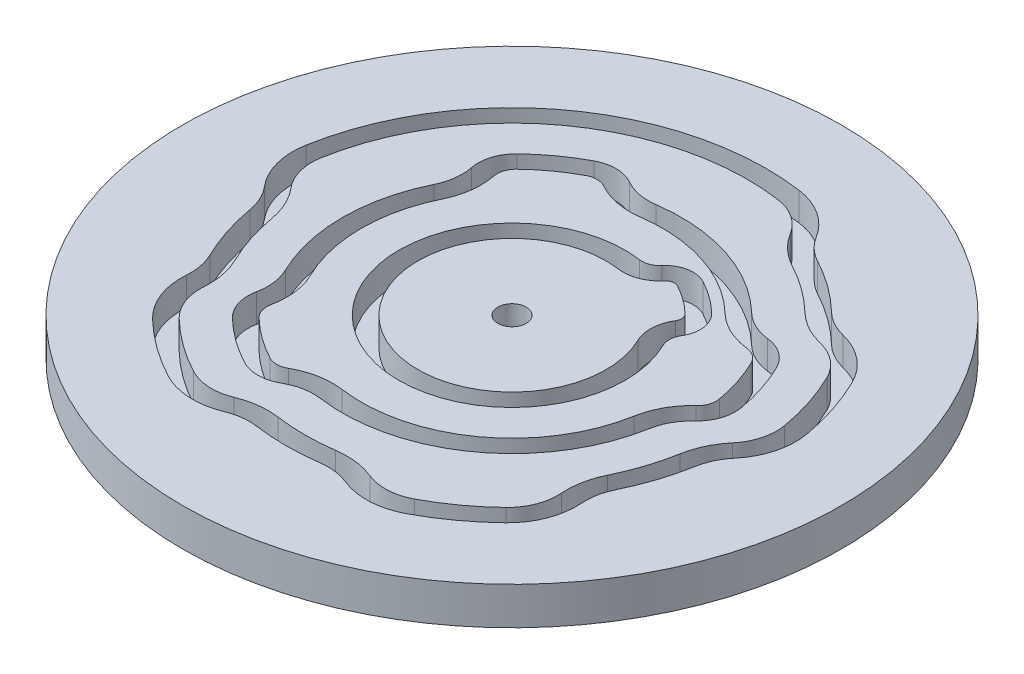
from build123d import *

# Parameters (mm, degrees)
EXTRUDE_1_DEPTH     = 3
EXTRUDE_1_2_DEPTH   = 3
EXTRUDE_1_3_DEPTH   = 3
SKETCH_2_R          = 35
EXTRUDE_1_4_DEPTH   = 3
SKETCH_3_R          = 35
EXTRUDE_2_DEPTH     = 1
SKETCH_4_R          = 1.505
CUT_EXTRUDE_1_DEPTH = 5


with BuildPart() as part:
    # 草图2 → 凸台-拉伸1 (new body)
    with BuildSketch(Plane(origin=(0, 0, 0), x_dir=(1, 0, 0), z_dir=(0, 1, 0))):
        with BuildLine():
            ThreePointArc((4.933437269, 11.253544382), (3.336493541, 10.122155344), (1.39173101, 9.902680687))
            ThreePointArc((1.39173101, 9.902680687), (-5.877852523, -8.090169944), (8.987940463, 4.383711468))
            ThreePointArc((8.987940463, 4.383711468), (8.595708593, 6.301111944), (9.178240759, 8.169514123))
            ThreePointArc((9.178240759, 8.169514123), (9.312956952, 8.786525533), (9.030558816, 9.351417404))
            ThreePointArc((9.030558816, 9.351417404), (7.64120828, 10.517220927), (6.103130316, 11.478318707))
            ThreePointArc((6.103130316, 11.478318707), (5.478620398, 11.572334106), (4.933437269, 11.253544382))
        make_face()
    extrude(amount=EXTRUDE_1_DEPTH)



with BuildPart() as body_2:
    # 草图2 → Extrude 1 2 (new body)
    with BuildSketch(Plane(origin=(0, 0, 0), x_dir=(1, 0, 0), z_dir=(0, 1, 0))):
        with BuildLine():
            ThreePointArc((-2.226769615, -15.8442891), (4.94427191, -15.216904261), (11.114533927, -11.509436805))
            ThreePointArc((11.114533927, -11.509436805), (14.127161486, -7.511545005), (15.756924048, -2.778370843))
            ThreePointArc((15.756924048, -2.778370843), (16.57293705, -0.458749656), (18.091681962, 1.475141128))
            ThreePointArc((18.091681962, 1.475141128), (18.635380141, 2.307784992), (18.711347307, 3.299315376))
            ThreePointArc((18.711347307, 3.299315376), (18.07007381, 5.871322893), (17.07708688, 8.329051789))
            ThreePointArc((17.07708688, 8.329051789), (16.432821214, 9.08656434), (15.503544365, 9.440609604))
            ThreePointArc((15.503544365, 9.440609604), (13.138141438, 10.112464253), (11.114533927, 11.509436805))
            ThreePointArc((11.114533927, 11.509436805), (4.94427191, 15.216904261), (-2.226769615, 15.8442891))
            ThreePointArc((-2.226769615, 15.8442891), (-4.685022346, 15.903561216), (-6.993579766, 16.750368343))
            ThreePointArc((-6.993579766, 16.750368343), (-7.953483115, 17.010154935), (-8.919959693, 16.776004264))
            ThreePointArc((-8.919959693, 16.776004264), (-11.167919794, 15.371322893), (-13.198509039, 13.667456206))
            ThreePointArc((-13.198509039, 13.667456206), (-13.719857247, 12.820638895), (-13.769411964, 11.827438089))
            ThreePointArc((-13.769411964, 11.827438089), (-13.677434002, 9.370191718), (-14.380704741, 7.013938349))
            ThreePointArc((-14.380704741, 7.013938349), (-16, 0), (-14.380704741, -7.013938349))
            ThreePointArc((-14.380704741, -7.013938349), (-13.677434002, -9.370191718), (-13.769411964, -11.827438089))
            ThreePointArc((-13.769411964, -11.827438089), (-13.719857247, -12.820638895), (-13.198509039, -13.667456206))
            ThreePointArc((-13.198509039, -13.667456206), (-11.167919794, -15.371322893), (-8.919959693, -16.776004264))
            ThreePointArc((-8.919959693, -16.776004264), (-7.953483115, -17.010154935), (-6.993579766, -16.750368343))
            ThreePointArc((-6.993579766, -16.750368343), (-4.685022346, -15.903561216), (-2.226769615, -15.8442891))
        make_face()
        with BuildLine():
            ThreePointArc((10.785528556, 5.260453761), (10.593186617, 6.200705058), (10.878847662, 7.116928659))
            ThreePointArc((10.878847662, 7.116928659), (11.297524269, 9.034502472), (10.419875557, 10.790097005))
            ThreePointArc((10.419875557, 10.790097005), (8.816778784, 12.135254916), (7.042073442, 13.244213893))
            ThreePointArc((7.042073442, 13.244213893), (5.101195454, 13.536398874), (3.40685257, 12.545650862))
            ThreePointArc((3.40685257, 12.545650862), (2.623746261, 11.990842401), (1.670077212, 11.883216825))
            ThreePointArc((1.670077212, 11.883216825), (-7.053423028, -9.708203932), (10.785528556, 5.260453761))
        make_face(mode=Mode.SUBTRACT)
    extrude(amount=EXTRUDE_1_2_DEPTH)


with BuildPart() as body_3:
    # 草图2 → Extrude 1 3 (new body)
    with BuildSketch(Plane(origin=(0, 0, 0), x_dir=(1, 0, 0), z_dir=(0, 1, 0))):
        with BuildLine():
            ThreePointArc((22.469851157, 10.95927867), (23.776412907, 7.725424859), (24.620193825, 4.341204442))
            ThreePointArc((24.620193825, 4.341204442), (24.516588458, 2.018942005), (23.437340957, -0.039907608))
            ThreePointArc((23.437340957, -0.039907608), (22.300880056, -1.81261067), (21.665770566, -3.820259909))
            ThreePointArc((21.665770566, -3.820259909), (20.923243358, -6.798373876), (19.773469019, -9.644165229))
            ThreePointArc((19.773469019, -9.644165229), (19.107216775, -11.641695573), (18.98466424, -13.743837434))
            ThreePointArc((18.98466424, -13.743837434), (18.647632371, -16.043847525), (17.366459261, -17.983495008))
            ThreePointArc((17.366459261, -17.983495008), (14.694631307, -20.225424859), (11.73678907, -22.073689821))
            ThreePointArc((11.73678907, -22.073689821), (9.496170427, -22.69277382), (7.204582268, -22.302567971))
            ThreePointArc((7.204582268, -22.302567971), (5.167455737, -21.769524797), (3.061808221, -21.785897512))
            ThreePointArc((3.061808221, -21.785897512), (0, -22), (-3.061808221, -21.785897512))
            ThreePointArc((-3.061808221, -21.785897512), (-5.167455737, -21.769524797), (-7.204582268, -22.302567971))
            ThreePointArc((-7.204582268, -22.302567971), (-9.496170427, -22.69277382), (-11.73678907, -22.073689821))
            ThreePointArc((-11.73678907, -22.073689821), (-14.694631307, -20.225424859), (-17.366459261, -17.983495008))
            ThreePointArc((-17.366459261, -17.983495008), (-18.647632371, -16.043847525), (-18.98466424, -13.743837434))
            ThreePointArc((-18.98466424, -13.743837434), (-19.107216775, -11.641695573), (-19.773469019, -9.644165229))
            ThreePointArc((-19.773469019, -9.644165229), (-20.923243358, -6.798373876), (-21.665770566, -3.820259909))
            ThreePointArc((-21.665770566, -3.820259909), (-22.300880056, -1.81261067), (-23.437340957, -0.039907608))
            ThreePointArc((-23.437340957, -0.039907608), (-24.516588458, 2.018942005), (-24.620193825, 4.341204442))
            ThreePointArc((-24.620193825, 4.341204442), (-14.694631307, 20.225424859), (3.479327524, 24.756701719))
            ThreePointArc((3.479327524, 24.756701719), (5.655914528, 23.9405486), (7.280491049, 22.277903712))
            ThreePointArc((7.280491049, 22.277903712), (8.615246116, 20.649269795), (10.328374381, 19.424847043))
            ThreePointArc((10.328374381, 19.424847043), (12.93127555, 17.798373876), (15.28248415, 15.825475607))
            ThreePointArc((15.28248415, 15.825475607), (16.976365134, 14.574561246), (18.937750033, 13.8084093))
            ThreePointArc((18.937750033, 13.8084093), (21.021041042, 12.777130739), (22.469851157, 10.95927867))
        make_face()
        with BuildLine():
            ThreePointArc((12.503850668, -12.948116406), (15.893056671, -8.45048813), (17.726539554, -3.125667198))
            ThreePointArc((17.726539554, -3.125667198), (18.326181707, -1.421107788), (19.442222095, 0))
            ThreePointArc((19.442222095, 0), (20.529100807, 1.664494981), (20.680962813, 3.646611731))
            ThreePointArc((20.680962813, 3.646611731), (19.972186842, 6.489356882), (18.874674972, 9.205794083))
            ThreePointArc((18.874674972, 9.205794083), (17.586757035, 10.72009797), (15.729088083, 11.427851419))
            ThreePointArc((15.729088083, 11.427851419), (13.990886243, 11.921559689), (12.503850668, 12.948116406))
            ThreePointArc((12.503850668, 12.948116406), (5.562305899, 17.119017293), (-2.505115817, 17.824825237))
            ThreePointArc((-2.505115817, 17.824825237), (-4.311547767, 17.868380988), (-6.007977036, 18.490652015))
            ThreePointArc((-6.007977036, 18.490652015), (-7.926869827, 19.00997786), (-9.858902819, 18.54189945))
            ThreePointArc((-9.858902819, 18.54189945), (-12.343490298, 16.989356882), (-14.58782578, 15.106135807))
            ThreePointArc((-14.58782578, 15.106135807), (-15.63002583, 13.413307424), (-15.729088083, 11.427851419))
            ThreePointArc((-15.729088083, 11.427851419), (-15.661498642, 9.622158987), (-16.178292833, 7.890680642))
            ThreePointArc((-16.178292833, 7.890680642), (-18, 0), (-16.178292833, -7.890680642))
            ThreePointArc((-16.178292833, -7.890680642), (-15.661498642, -9.622158987), (-15.729088083, -11.427851419))
            ThreePointArc((-15.729088083, -11.427851419), (-15.63002583, -13.413307424), (-14.58782578, -15.106135807))
            ThreePointArc((-14.58782578, -15.106135807), (-12.343490298, -16.989356882), (-9.858902819, -18.54189945))
            ThreePointArc((-9.858902819, -18.54189945), (-7.926869827, -19.00997786), (-6.007977036, -18.490652015))
            ThreePointArc((-6.007977036, -18.490652015), (-4.311547767, -17.868380988), (-2.505115817, -17.824825237))
            ThreePointArc((-2.505115817, -17.824825237), (5.562305899, -17.119017293), (12.503850668, -12.948116406))
        make_face(mode=Mode.SUBTRACT)
    extrude(amount=EXTRUDE_1_3_DEPTH)


with BuildPart() as body_4:
    # 草图2 → Extrude 1 4 (new body)
    with BuildSketch(Plane(origin=(0, 0, 0), x_dir=(1, 0, 0), z_dir=(0, 1, 0))):
        Circle(SKETCH_2_R)
        with BuildLine():
            ThreePointArc((-21.571057111, -10.520907523), (-21.071193566, -12.019578048), (-20.979247092, -13.596734588))
            ThreePointArc((-20.979247092, -13.596734588), (-20.516153338, -16.757030106), (-18.755776002, -19.422174609))
            ThreePointArc((-18.755776002, -19.422174609), (-15.870201812, -21.843458848), (-12.675732195, -23.839585007))
            ThreePointArc((-12.675732195, -23.839585007), (-9.597042635, -24.6902284), (-6.448319149, -24.15407171))
            ThreePointArc((-6.448319149, -24.15407171), (-4.919941122, -23.754149829), (-3.340154423, -23.76643365))
            ThreePointArc((-3.340154423, -23.76643365), (0, -24), (3.340154423, -23.76643365))
            ThreePointArc((3.340154423, -23.76643365), (4.919941122, -23.754149829), (6.448319149, -24.15407171))
            ThreePointArc((6.448319149, -24.15407171), (9.597042635, -24.6902284), (12.675732195, -23.839585007))
            ThreePointArc((12.675732195, -23.839585007), (15.870201812, -21.843458848), (18.755776002, -19.422174609))
            ThreePointArc((18.755776002, -19.422174609), (20.516153338, -16.757030106), (20.979247092, -13.596734588))
            ThreePointArc((20.979247092, -13.596734588), (21.071193566, -12.019578048), (21.571057111, -10.520907523))
            ThreePointArc((21.571057111, -10.520907523), (22.825356391, -7.416407865), (23.635386072, -4.167556264))
            ThreePointArc((23.635386072, -4.167556264), (24.111884402, -2.66129392), (24.964527497, -1.331302695))
            ThreePointArc((24.964527497, -1.331302695), (26.447451878, 1.497629765), (26.589809331, 4.688500797))
            ThreePointArc((26.589809331, 4.688500797), (25.67852594, 8.343458848), (24.26743925, 11.836020963))
            ThreePointArc((24.26743925, 11.836020963), (22.276722717, 14.333814244), (19.414206911, 15.750827598))
            ThreePointArc((19.414206911, 15.750827598), (17.942654929, 16.325642065), (16.671800891, 17.264155208))
            ThreePointArc((16.671800891, 17.264155208), (14.106846055, 19.416407865), (11.267317507, 21.190742229))
            ThreePointArc((11.267317507, 21.190742229), (9.982022971, 22.109379732), (8.980607357, 23.331281394))
            ThreePointArc((8.980607357, 23.331281394), (6.748381541, 25.615814497), (3.757673726, 26.737237856))
            ThreePointArc((3.757673726, 26.737237856), (-15.870201812, 21.843458848), (-26.589809331, 4.688500797))
            ThreePointArc((-26.589809331, 4.688500797), (-26.447451878, 1.497629765), (-24.964527497, -1.331302695))
            ThreePointArc((-24.964527497, -1.331302695), (-24.111884402, -2.66129392), (-23.635386072, -4.167556264))
            ThreePointArc((-23.635386072, -4.167556264), (-22.825356391, -7.416407865), (-21.571057111, -10.520907523))
        make_face(mode=Mode.SUBTRACT)
    extrude(amount=EXTRUDE_1_4_DEPTH)


with BuildPart() as part_1:
    add(part.part)

    add(body_2.part)  # 凸台-拉伸2 merges body 2

    add(body_3.part)  # 凸台-拉伸2 merges body 3

    add(body_4.part)  # 凸台-拉伸2 merges body 4
    # 草图3 → 凸台-拉伸2 (add)
    with BuildSketch(Plane.XZ):
        Circle(SKETCH_3_R)
    extrude(amount=EXTRUDE_2_DEPTH)

    # 草图4 → 切除-拉伸1 (cut, through all)
    with BuildSketch(Plane(origin=(0, 3, 0), x_dir=(1, 0, 0), z_dir=(0, 1, 0))):
        Circle(SKETCH_4_R)
    extrude(amount=-CUT_EXTRUDE_1_DEPTH, mode=Mode.SUBTRACT)


solid = part_1.part
